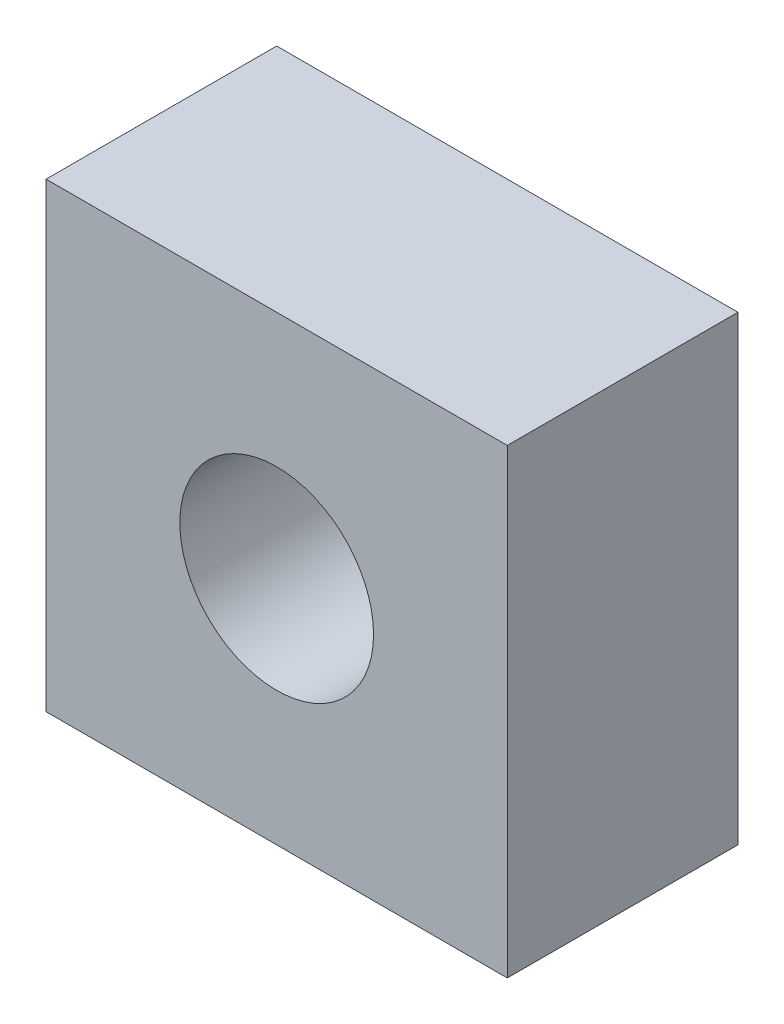
from build123d import *

# Parameters (mm, degrees)
SKETCH1_W           = 10
SKETCH1_H           = 10
SKETCH1_R           = 2.1
BOSS_EXTRUDE1_DEPTH = 5


with BuildPart() as part:
    # Sketch1 → Boss-Extrude1 (new body)
    with BuildSketch(Plane.XY):
        with Locations((-5, 5)):
            Rectangle(SKETCH1_W, SKETCH1_H)
        with Locations((-5, 5)):
            Circle(SKETCH1_R, mode=Mode.SUBTRACT)
    extrude(amount=BOSS_EXTRUDE1_DEPTH)


solid = part.part
